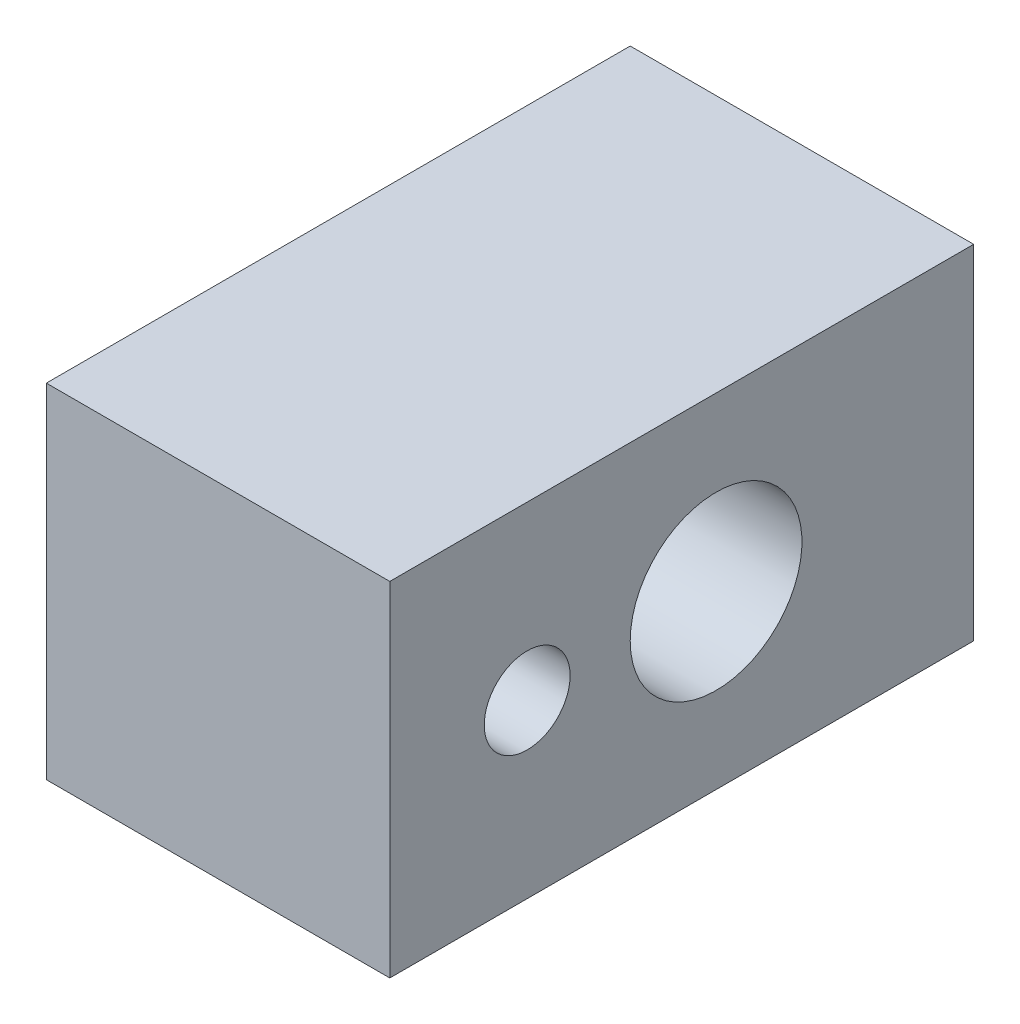
from build123d import *

# Parameters (mm, degrees)
ESQUISSE1_W               = 10
ESQUISSE1_H               = 10
EXTRUSION1_DEPTH          = 17
ESQUISSE2_R               = 2.5
ENL_V_MAT_EXTRU_1_DEPTH   = 11
TROU_TARAUD_M3X0_51_D     = 2.5
TROU_TARAUD_M4X0_71_D     = 3.3
TROU_TARAUD_M4X0_71_DEPTH = 8
TROU_TARAUD_M4X0_71_TIP   = 0.991420021


with BuildPart() as part:
    # Esquisse1 → Extrusion1 (new body)
    with BuildSketch(Plane.XY):
        with Locations((-5, 5)):
            Rectangle(ESQUISSE1_W, ESQUISSE1_H)
    extrude(amount=EXTRUSION1_DEPTH)

    # Esquisse2 → Enlèv. mat.-Extru.1 (cut, through all)
    with BuildSketch(Plane(origin=(0, 0, 0), x_dir=(0, 0, -1), z_dir=(1, 0, 0))):
        with Locations(Location((-7.5, 5, 0), (0, 0, 180))):  # turned: the seam where the file's is
            Circle(ESQUISSE2_R)
    extrude(amount=-ENL_V_MAT_EXTRU_1_DEPTH, mode=Mode.SUBTRACT)

    # Trou taraudé M3x0.51 (through all)
    with Locations(Plane(origin=(0, 5, 13), x_dir=(0, 0, 1), z_dir=(1, 0, 0))):
        with Locations((0, 0)):
            Hole(TROU_TARAUD_M3X0_51_D / 2)

    # Trou taraudé M4x0.71
    with Locations(Plane(origin=(-5, 5, 0), x_dir=(-1, 0, 0), z_dir=(0, 0, -1))):
        with Locations((0, 0)):
            Hole(TROU_TARAUD_M4X0_71_D / 2, depth=TROU_TARAUD_M4X0_71_DEPTH)
            with Locations((0, 0, -(TROU_TARAUD_M4X0_71_DEPTH + TROU_TARAUD_M4X0_71_TIP / 2))):  # 118° drill point
                Cone(0, TROU_TARAUD_M4X0_71_D / 2, TROU_TARAUD_M4X0_71_TIP, mode=Mode.SUBTRACT)


solid = part.part
